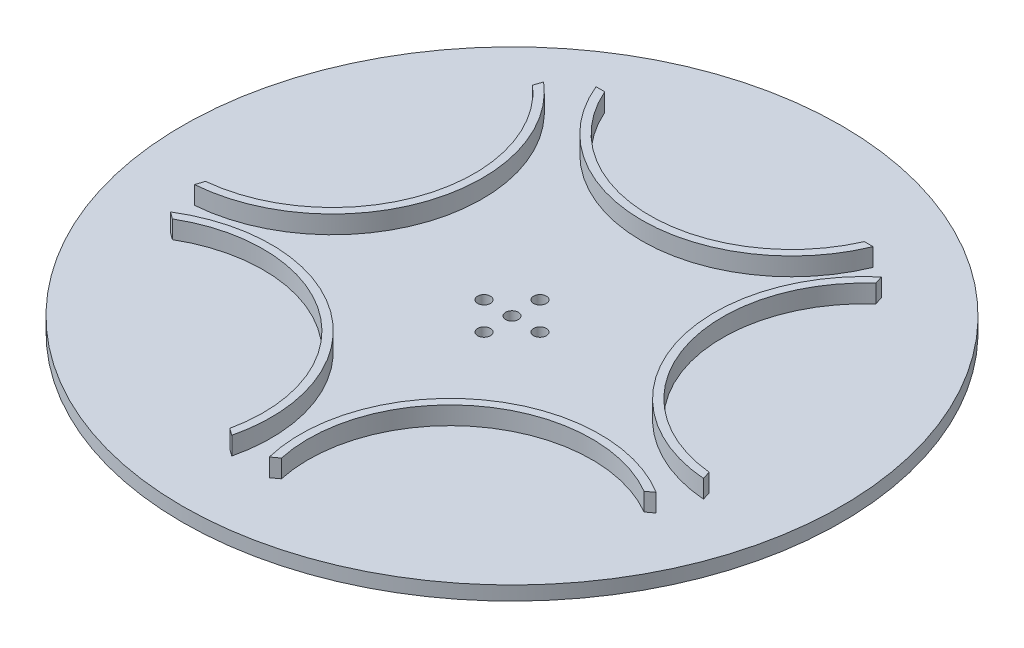
from build123d import *

# Parameters (mm, degrees)
SKETCH_2_R      = 82.5
SKETCH_2_R_2    = 1.6
EXTRUDE_1_DEPTH = 3.5
EXTRUDE_2_DEPTH = 8


with BuildPart() as part:
    # 草图2 → 凸台-拉伸1 (new body)
    with BuildSketch(Plane(origin=(0, 0, 0), x_dir=(1, 0, 0), z_dir=(0, 1, 0))):
        Circle(SKETCH_2_R)
        with Locations((0, -7)):
            Circle(SKETCH_2_R_2, mode=Mode.SUBTRACT)
        with Locations((-7, 0)):
            Circle(SKETCH_2_R_2, mode=Mode.SUBTRACT)
        Circle(SKETCH_2_R_2, mode=Mode.SUBTRACT)
        with Locations((7, 0)):
            Circle(SKETCH_2_R_2, mode=Mode.SUBTRACT)
        with Locations((0, 7)):
            Circle(SKETCH_2_R_2, mode=Mode.SUBTRACT)
    extrude(amount=EXTRUDE_1_DEPTH)

    # 草图2<3> → 凸台-拉伸2 (add)
    with BuildSketch(Plane(origin=(0, 0, 0), x_dir=(1, 0, 0), z_dir=(0, 1, 0))):
        with BuildLine():
            ThreePointArc((32.5, 55.717143143), (0, 34.5), (-32.5, 55.717143143))
            Line((-32.5, 55.717143143), (-34.673476895, 55.717143143))
            ThreePointArc((-34.673476895, 55.717143143), (0, 32.5), (34.673476895, 55.717143143))
            Line((34.673476895, 55.717143143), (32.5, 55.717143143))
        make_face()
        with BuildLine():
            ThreePointArc((63.033204373, -13.69179267), (32.811449812, 10.661086306), (42.947099738, 48.126880889))
            Line((42.947099738, 48.126880889), (42.275458441, 50.193980253))
            ThreePointArc((42.275458441, 50.193980253), (30.90933678, 10.043052317), (63.70484567, -15.758892035))
            Line((63.70484567, -15.758892035), (63.033204373, -13.69179267))
        make_face()
        with BuildLine():
            ThreePointArc((6.456662722, -64.17913638), (20.278591204, -27.911086306), (59.042767356, -25.973094981))
            Line((59.042767356, -25.973094981), (60.801147102, -24.695557316))
            ThreePointArc((60.801147102, -24.695557316), (19.1030207, -26.293052317), (4.698282977, -65.456674045))
            Line((4.698282977, -65.456674045), (6.456662722, -64.17913638))
        make_face()
        with BuildLine():
            ThreePointArc((-59.042767356, -25.973094981), (-20.278591204, -27.911086306), (-6.456662722, -64.17913638))
            Line((-6.456662722, -64.17913638), (-4.698282977, -65.456674045))
            ThreePointArc((-4.698282977, -65.456674045), (-19.1030207, -26.293052317), (-60.801147102, -24.695557316))
            Line((-60.801147102, -24.695557316), (-59.042767356, -25.973094981))
        make_face()
        with BuildLine():
            ThreePointArc((-42.947099738, 48.126880889), (-32.811449812, 10.661086306), (-63.033204373, -13.69179267))
            Line((-63.033204373, -13.69179267), (-63.70484567, -15.758892035))
            ThreePointArc((-63.70484567, -15.758892035), (-30.90933678, 10.043052317), (-42.275458441, 50.193980253))
            Line((-42.275458441, 50.193980253), (-42.947099738, 48.126880889))
        make_face()
    extrude(amount=EXTRUDE_2_DEPTH)


solid = part.part
